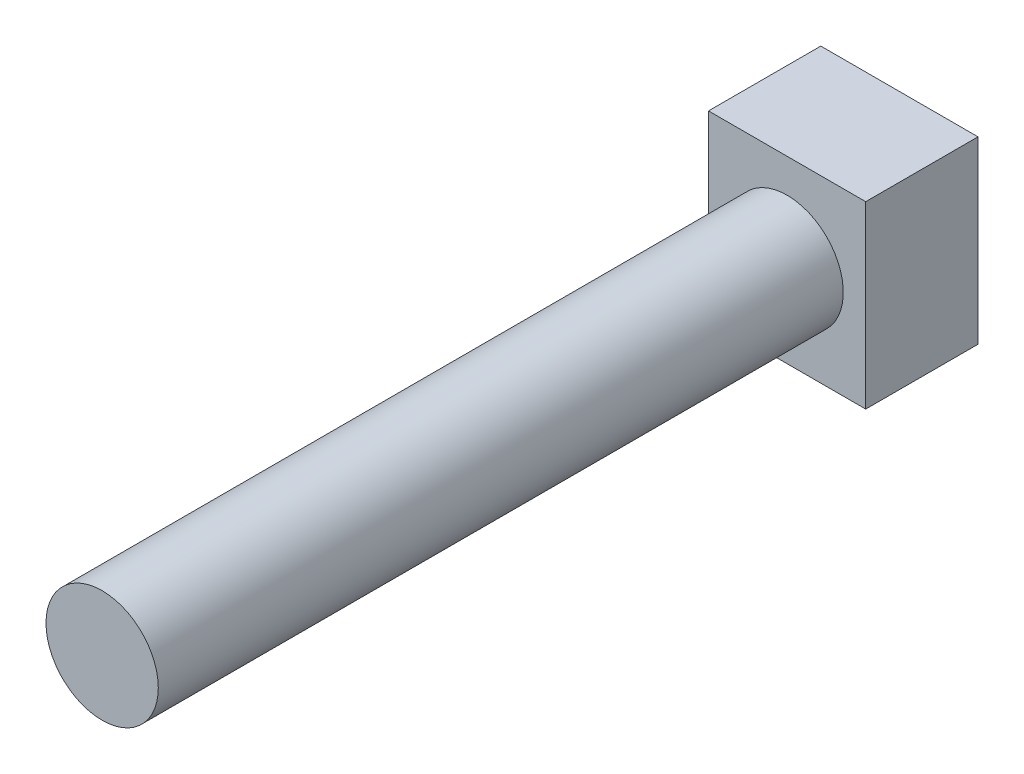
from build123d import *

# Parameters (mm, degrees)
SKETCH2_R           = 2.5
BOSS_EXTRUDE1_DEPTH = 35.5
SKETCH4_W           = 7
SKETCH4_H           = 8
BOSS_EXTRUDE4_DEPTH = 5


with BuildPart() as part:
    # Sketch2 → Boss-Extrude1 (new body)
    with BuildSketch(Plane.XY):
        Circle(SKETCH2_R)
    extrude(amount=BOSS_EXTRUDE1_DEPTH)

    # Sketch4 → Boss-Extrude4 (add)
    with BuildSketch(Plane(origin=(0, 0, 0), x_dir=(-1, 0, 0), z_dir=(0, 0, -1))):
        Rectangle(SKETCH4_W, SKETCH4_H)
    extrude(amount=-BOSS_EXTRUDE4_DEPTH)


solid = part.part
